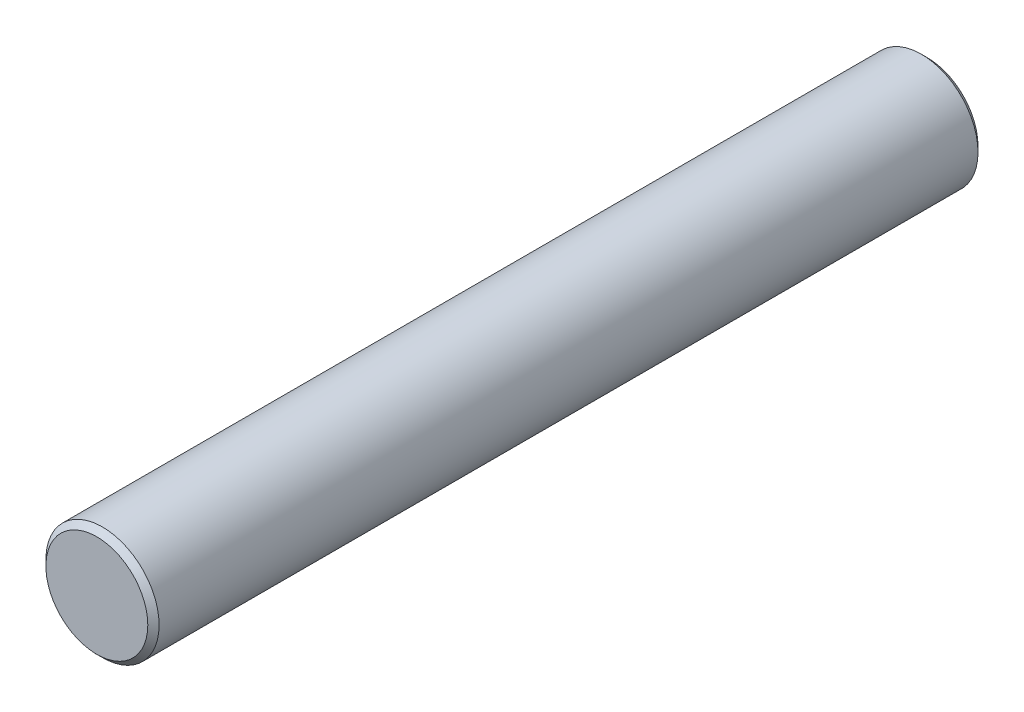
from build123d import *

# Parameters (mm, degrees)
SKETCH1_R           = 1.5
BOSS_EXTRUDE1_DEPTH = 11
CHAMFER1_SIZE       = 0.15


with BuildPart() as part:
    # Sketch1 → Boss-Extrude1 (new body, symmetric)
    with BuildSketch(Plane.XY):
        Circle(SKETCH1_R)
    extrude(amount=BOSS_EXTRUDE1_DEPTH, both=True)

    # Chamfer1
    chamfer1_edges = [part.edges().sort_by_distance(p)[0] for p in [
        (-1.5, 0, -11),
        (-1.5, 0, 11),
    ]]
    chamfer(chamfer1_edges, length=CHAMFER1_SIZE)


solid = part.part
